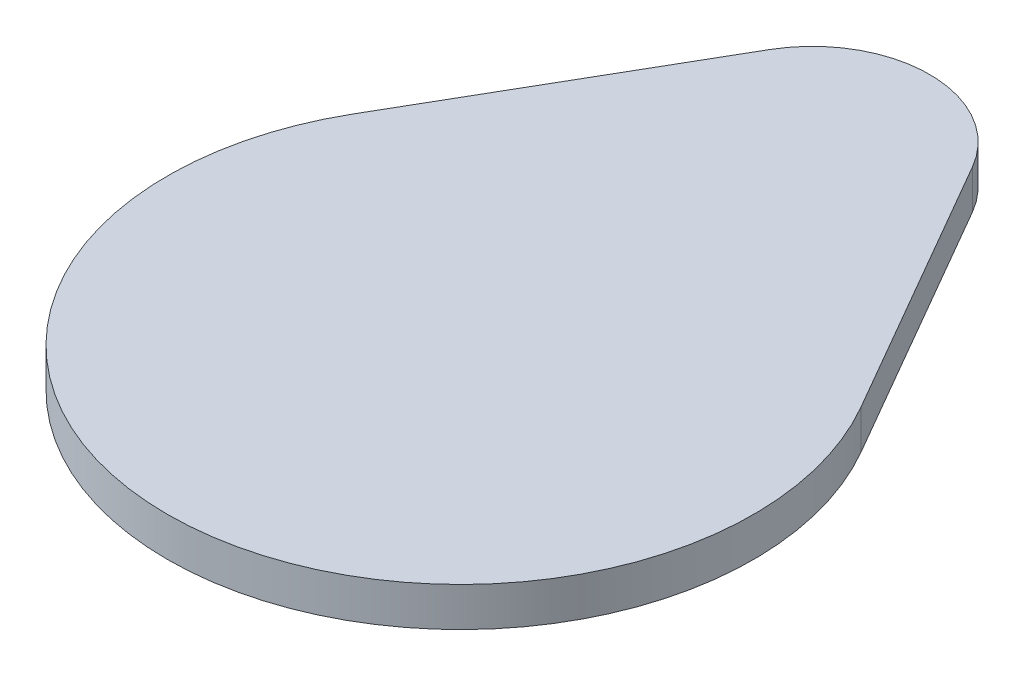
from build123d import *

# Parameters (mm, degrees)
BOSS_EXTRUDE1_DEPTH = 1
FILLET1_R           = 3


with BuildPart() as part:
    # Sketch1 → Boss-Extrude1 (new body)
    with BuildSketch(Plane(origin=(0, 0, 0), x_dir=(1, 0, 0), z_dir=(0, 1, 0))):
        with BuildLine():
            Line((6.495190528, 3.75), (0, 15))
            Line((0, 15), (-6.495190528, 3.75))
            ThreePointArc((-6.495190528, 3.75), (0, -7.5), (6.495190528, 3.75))
        make_face()
    extrude(amount=BOSS_EXTRUDE1_DEPTH)

    # Fillet1
    fillet1_edges = [part.edges().sort_by_distance(p)[0] for p in [
        (0, 0.5, -15),
    ]]
    fillet(fillet1_edges, radius=FILLET1_R)


solid = part.part
